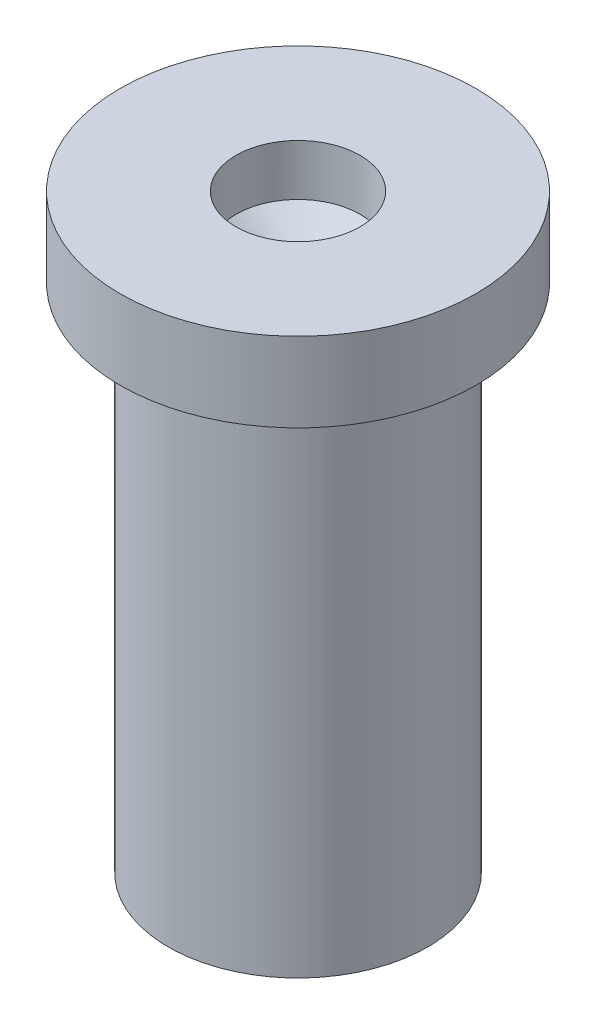
from build123d import *


with BuildPart() as part:
    # Sketch1 → Revolve1 (revolve)
    with BuildSketch(Plane.XY):
        Polygon((0, 0), (3.1, 0), (3.1, 12.2), (4.250358509, 12.2), (4.250358509, 14.096320757), (1.482525951, 14.096320757), (1.482525951, 12.875218158), (0, 11.877522571), align=None)
    revolve(axis=Axis((0, 0, 0), (0, 1, 0)))


solid = part.part
